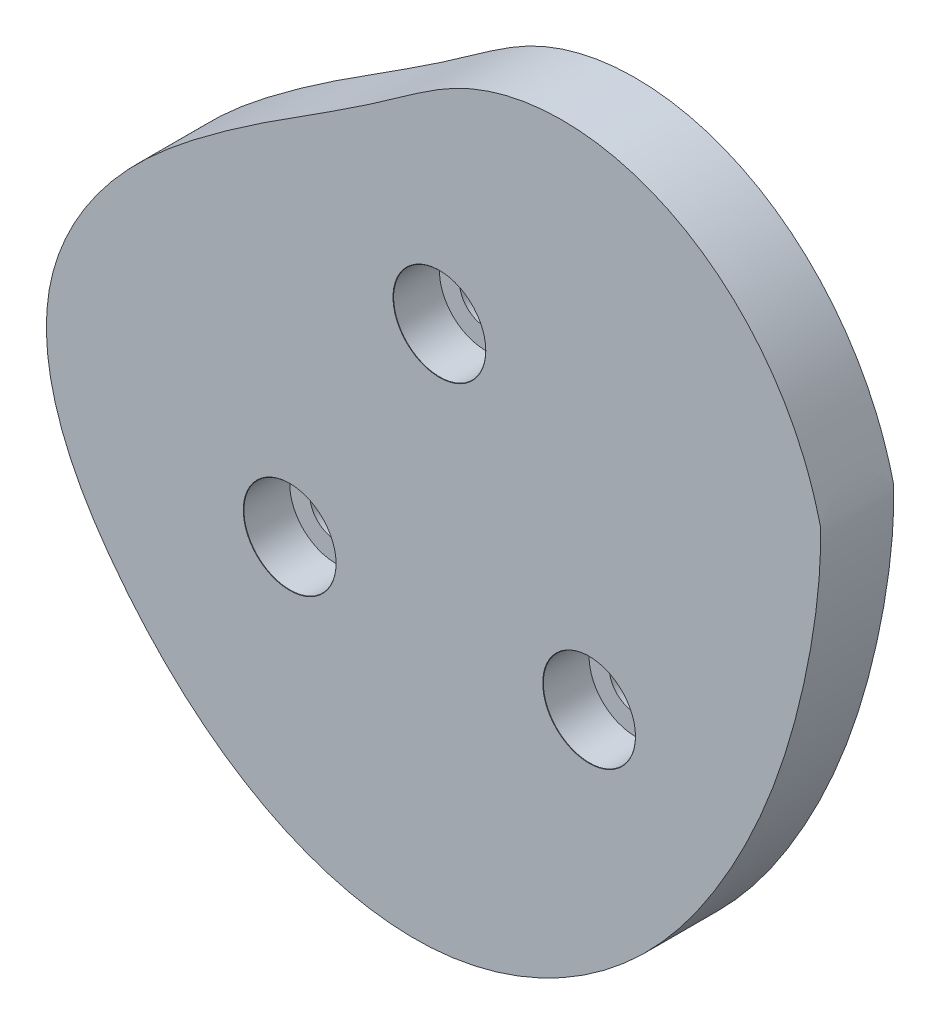
from build123d import *

# Parameters (mm, degrees)
BOSS_EXTRUDE1_DEPTH           = 3.175
CBORE_FOR_M4_SHCS1_AT_2_COUNT = 2
CBORE_FOR_M4_SHCS1_AT_2_PITCH = 25.980762114
CBORE_FOR_M4_SHCS1_AT_3_COUNT = 2
CBORE_FOR_M4_SHCS1_AT_3_PITCH = 25.980762114


with BuildPart() as part:
    # Sketch1 → Boss-Extrude1 (new body, symmetric)
    with BuildSketch(Plane.XY):
        with BuildLine():
            add(Edge.make_bspline(
                [(20.469276515, 0), (20.453926982, 0.12032637), (20.37906939, 0.354674879), (20.296830063, 0.708499092), (20.201433403, 1.058274137), (20.104513169, 1.405451482), (20.003039964, 1.749648928), (19.897882185, 2.090972241), (19.788868962, 2.429397518), (19.676103633, 2.764935406), (19.559614296, 3.097587319), (19.439446847, 3.427357), (19.315640263, 3.754247363), (19.18823323, 4.078261244), (19.057262426, 4.399401123), (18.922763033, 4.717669117), (18.784768655, 5.033066908), (18.643311395, 5.345595684), (18.498421896, 5.655256084), (18.350129388, 5.962048143), (18.198461741, 6.265971239), (18.043445514, 6.567024042), (17.885106009, 6.865204466), (17.723467325, 7.160509621), (17.558552411, 7.452935769), (17.390383125, 7.742478283), (17.218980293, 8.029131604), (17.044363762, 8.312889204), (16.866552466, 8.593743551), (16.685564483, 8.871686073), (16.501417094, 9.146707128), (16.314126853, 9.418795975), (16.123709641, 9.687940747), (15.930180735, 9.954128423), (15.73355487, 10.21734481), (15.533846304, 10.477574522), (15.331068884, 10.734800958), (15.125236108, 10.989006292), (14.916361195, 11.240171456), (14.704457148, 11.48827613), (14.48953682, 11.733298735), (14.271612982, 11.975216425), (14.050698387, 12.214005082), (13.826805837, 12.449639318), (13.599948249, 12.682092471), (13.37013872, 12.911336613), (13.137390595, 13.137342549), (12.901717528, 13.360079832), (12.66313355, 13.579516764), (12.42165313, 13.795620417), (12.177291245, 14.00835664), (11.930063436, 14.21769008), (11.679985874, 14.423584196), (11.427075422, 14.626001285), (11.171349697, 14.824902501), (10.912827125, 15.020247881), (10.651527006, 15.211996372), (10.387469571, 15.400105862), (10.120676038, 15.584533205), (9.851168668, 15.765234263), (9.578970821, 15.942163933), (9.30410701, 16.115276188), (9.026602952, 16.284524115), (8.746485624, 16.449859953), (8.463783305, 16.611235142), (8.178525632, 16.768600359), (7.890743643, 16.921905569), (7.600469825, 17.071100071), (7.307738154, 17.216132546), (7.012584144, 17.356951111), (6.71504488, 17.493503366), (6.415159063, 17.625736452), (6.112967045, 17.753597106), (5.808510864, 17.877031712), (5.501834279, 17.995986365), (5.192982801, 18.110406928), (4.882003722, 18.22023909), (4.568946147, 18.32542843), (4.253861014, 18.425920478), (3.936801123, 18.521660778), (3.617821156, 18.612594954), (3.296977698, 18.698668773), (2.974329252, 18.779828214), (2.649936258, 18.856019533), (2.323861105, 18.927189329), (1.996168144, 18.993284617), (1.666923695, 19.054252892), (1.336196056, 19.110042202), (1.004055505, 19.160601215), (0.670574308, 19.205879292), (0.335826712, 19.245826554), (-0.000111049, 19.280393959), (-0.337160764, 19.309533366), (-0.675242249, 19.33319761), (-1.014273357, 19.351340575), (-1.354169986, 19.36391726), (-1.694846096, 19.370883857), (-2.036213723, 19.372197815), (-2.378182996, 19.367817918), (-2.720662158, 19.357704349), (-3.06355759, 19.341818766), (-3.406773832, 19.320124369), (-3.750213613, 19.29258597), (-4.093777879, 19.259170061), (-4.437365826, 19.219844885), (-4.780874932, 19.174580501), (-5.124200991, 19.123348854), (-5.467238158, 19.066123837), (-5.809878982, 19.002881361), (-6.152014452, 18.933599416), (-6.493534041, 18.858258136), (-6.834325754, 18.776839862), (-7.174276174, 18.689329199), (-7.513270515, 18.595713085), (-7.851192674, 18.49598084), (-8.187925289, 18.39012423), (-8.52334979, 18.278137522), (-8.857346463, 18.160017536), (-9.18979451, 18.035763705), (-9.520572102, 17.905378106), (-9.849556485, 17.76886559), (-10.176623887, 17.626233534), (-10.501650192, 17.477492989), (-10.824508724, 17.322654615), (-11.145080224, 17.161743427), (-11.463230747, 16.994735948), (-11.779050897, 16.821987195), (-12.092717082, 16.643916451), (-12.40442328, 16.460901436), (-12.714391967, 16.273307346), (-13.022869092, 16.08147821), (-13.330124311, 15.885737879), (-13.636449754, 15.686388462), (-13.942159146, 15.48370949), (-14.247586785, 15.277956924), (-14.553086511, 15.069362251), (-14.859030639, 14.858131599), (-15.165808852, 14.64444489), (-15.473827068, 14.428455032), (-15.783506277, 14.210287148), (-16.095281345, 13.990037832), (-16.40959979, 13.767774461), (-16.72692054, 13.54353453), (-17.047712658, 13.317325034), (-17.372454053, 13.089121892), (-17.701630161, 12.858869404), (-18.035732622, 12.62647976), (-18.375257928, 12.391832591), (-18.720706063, 12.15477456), (-19.072579127, 11.915119006), (-19.43137995, 11.672645633), (-19.797610697, 11.427100253), (-20.171771452, 11.17819457), (-20.554358808, 10.925606023), (-20.94586444, 10.668977684), (-21.346773666, 10.407918194), (-21.757564012, 10.14200177), (-22.178703761, 9.870768248), (-22.6106505, 9.593723189), (-23.053849668, 9.310338029), (-23.508733094, 9.020050289), (-23.975717536, 8.722263829), (-24.455203223, 8.416349151), (-24.947572399, 8.101643764), (-25.453187868, 7.777452583), (-25.972391547, 7.443048392), (-26.505503025, 7.097672347), (-27.052818136, 6.74053453), (-27.614607536, 6.370814557), (-28.191115299, 5.98766223), (-28.782557525, 5.590198235), (-29.389120965, 5.1775149), (-30.01096166, 4.74867698), (-30.64820362, 4.302722541), (-31.300937436, 3.838663708), (-31.969219271, 3.355488182), (-32.653068482, 2.852157975), (-33.352355561, 2.327705554), (-34.066325533, 1.781561053), (-34.792156176, 1.21198818), (-35.526433511, 0.617909195), (-36.265587734, -0.001457622), (-37.006020345, -0.646671842), (-37.744112291, -1.318073183), (-38.476233993, -2.015780313), (-39.198754785, -2.739691012), (-39.908052424, -3.489482365), (-40.600522516, -4.264611377), (-41.272587879, -5.064315898), (-41.920707839, -5.8876159), (-42.541387444, -6.733315094), (-43.131186577, -7.600002901), (-43.686728957, -8.486056757), (-44.204711001, -9.389644786), (-44.681910487, -10.308728765), (-45.115195144, -11.241067557), (-45.501530481, -12.184220343), (-45.837989248, -13.135551967), (-46.121753439, -14.092231719), (-46.350171981, -15.051382919), (-46.520731563, -16.010470183), (-46.635259313, -16.966833368), (-46.695881182, -17.918707922), (-46.704758414, -18.864589252), (-46.664077675, -19.803116927), (-46.576039325, -20.733069832), (-46.442852564, -21.653366621), (-46.266728948, -22.563064411), (-46.04987654, -23.461357639), (-45.794494099, -24.347576614), (-45.502765451, -25.221185937), (-45.176853985, -26.081782762), (-44.818897277, -26.929094921), (-44.431001821, -27.762978927), (-44.015237852, -28.583417844), (-43.57363427, -29.390519034), (-43.108173634, -30.184511764), (-42.620787267, -30.965744674), (-42.113350378, -31.734683158), (-41.587677508, -32.491906358), (-41.045517213, -33.238104962), (-40.488554103, -33.974069902), (-39.918413965, -34.700676565), (-39.33481729, -35.417341816), (-38.737534614, -36.123431266), (-38.126368953, -36.818284488), (-37.501156774, -37.501216811), (-36.861768424, -38.171521432), (-36.208109378, -38.828470556), (-35.54012122, -39.471316853), (-34.857782619, -40.099294871), (-34.161110261, -40.711622507), (-33.450159719, -41.307502509), (-32.725026287, -41.886124006), (-31.985845748, -42.446664075), (-31.232795105, -42.98828933), (-30.466093242, -43.510157547), (-29.686001549, -44.011419305), (-28.892824481, -44.491219662), (-28.08691006, -44.948699845), (-27.268650333, -45.382998964), (-26.438481761, -45.793255749), (-25.596885557, -46.178610297), (-24.744387965, -46.538205845), (-23.881560483, -46.871190547), (-23.009020024, -47.176719273), (-22.127429019, -47.45395541), (-21.237495463, -47.702072683), (-20.339972901, -47.920256977), (-19.435660354, -48.10770816), (-18.525402181, -48.263641942), (-17.610087896, -48.387291641), (-16.690651874, -48.477910274), (-15.768073177, -48.534771472), (-14.84337466, -48.55717479), (-13.917624463, -48.544434556), (-12.991941631, -48.495930985), (-12.067628664, -48.41094298), (-11.146068248, -48.290046351), (-10.228680944, -48.134143741), (-9.316882792, -47.944122816), (-8.412028473, -47.72093942), (-7.515412754, -47.465590968), (-6.62826823, -47.179120315), (-5.751764231, -46.862611411), (-4.88700552, -46.517187103), (-4.03503117, -46.144006323), (-3.196813506, -45.744261393), (-2.373257143, -45.319175263), (-1.565198119, -44.86999873), (-0.773403127, -44.398007635), (0.001431168, -43.904500034), (0.758678706, -43.390793354), (1.497784521, -42.858221534), (2.218265124, -42.308132156), (2.919708798, -41.74188356), (3.601775788, -41.160841961), (4.2641984, -40.566378558), (4.906780999, -39.959866645), (5.529399907, -39.342678725), (6.132003211, -38.716183626), (6.714610467, -38.081743631), (7.277312313, -37.440711615), (7.82026998, -36.794428197), (8.343714715, -36.144218914), (8.847947092, -35.491391398), (9.333336294, -34.837232621), (9.800319062, -34.183006019), (10.24939942, -33.529949158), (10.681145161, -32.879269558), (11.096195715, -32.232147378), (11.49523197, -31.589707036), (11.879149859, -30.952992781), (12.248517048, -30.322552069), (12.603694342, -29.698556098), (12.945153788, -29.0811272), (13.273344314, -28.470359529), (13.588713491, -27.866335339), (13.891701075, -27.269121707), (14.182740239, -26.678771864), (14.462256803, -26.095325337), (14.730669009, -25.518808409), (14.988387177, -24.949234509), (15.2358134, -24.386604625), (15.473341258, -23.830907716), (15.701355534, -23.282121139), (15.920231962, -22.740211075), (16.130336972, -22.205132959), (16.332027463, -21.676831916), (16.525650586, -21.155243203), (16.711543541, -20.640292652), (16.890033391, -20.131897115), (17.061436892, -19.629964916), (17.226060335, -19.134396296), (17.384199405, -18.645083873), (17.536139055, -18.161913089), (17.682153396, -17.684762669), (17.822505599, -17.213505075), (17.957447815, -16.748006957), (18.087221108, -16.288129613), (18.212055405, -15.833729436), (18.332169455, -15.384658369), (18.447770812, -14.940764355), (18.559055824, -14.501891782), (18.666209639, -14.067881928), (18.769406229, -13.638573405), (18.868808423, -13.213802595), (18.964567955, -12.793404083), (19.056825528, -12.37721109), (19.14571089, -11.965055896), (19.231342923, -11.556770257), (19.313829749, -11.152185827), (19.393268841, -10.751134561), (19.469747157, -10.353449118), (19.543341277, -9.95896326), (19.614117561, -9.567512236), (19.682132311, -9.178933172), (19.747431952, -8.793065437), (19.810053221, -8.409751015), (19.870023364, -8.028834861), (19.927360353, -7.650165254), (19.982073105, -7.273594135), (20.034161718, -6.898977439), (20.083617711, -6.526175422), (20.130424277, -6.15505297), (20.174556549, -5.785479904), (20.215981868, -5.417331275), (20.254660065, -5.050487643), (20.290543747, -4.684835353), (20.323578606, -4.320266795), (20.353703685, -3.956680655), (20.380851823, -3.593982143), (20.404949486, -3.232083278), (20.425918912, -2.87090287), (20.443671673, -2.510367615), (20.458134208, -2.150408957), (20.469154396, -1.790975662), (20.476850973, -1.431987855), (20.480314085, -1.073508931), (20.482447125, -0.715105964), (20.47192834, -0.358233383), (20.484273463, -0.11756243), (20.469276515, 0)],
                knots=[0, 0, 0, 0, 0.001764203, 0.003519492, 0.005266096, 0.007004244, 0.008734164, 0.010456082, 0.01217022, 0.013876802, 0.015576046, 0.017268173, 0.018953398, 0.020631935, 0.022303998, 0.023969797, 0.025629542, 0.027283438, 0.02893169, 0.030574501, 0.032212071, 0.033844598, 0.035472279, 0.037095307, 0.038713875, 0.04032817, 0.041938381, 0.043544692, 0.045147285, 0.046746342, 0.048342038, 0.04993455, 0.05152405, 0.053110709, 0.054694695, 0.056276173, 0.057855307, 0.059432256, 0.061007179, 0.062580232, 0.064151567, 0.065721335, 0.067289683, 0.068856757, 0.070422701, 0.071987653, 0.073551752, 0.075115133, 0.076677929, 0.078240269, 0.079802281, 0.08136409, 0.082925818, 0.084487586, 0.08604951, 0.087611705, 0.089174283, 0.090737355, 0.092301027, 0.093865405, 0.09543059, 0.096996683, 0.09856378, 0.100131977, 0.101701366, 0.103272038, 0.10484408, 0.106417578, 0.107992614, 0.109569269, 0.111147622, 0.112727748, 0.114309722, 0.115893614, 0.117479494, 0.11906743, 0.120657485, 0.122249722, 0.123844203, 0.125440984, 0.127040123, 0.128641672, 0.130245685, 0.13185221, 0.133461296, 0.135072989, 0.136687331, 0.138304365, 0.139924131, 0.141546665, 0.143172005, 0.144800184, 0.146431233, 0.148065183, 0.149702063, 0.151341898, 0.152984714, 0.154630532, 0.156279374, 0.157931258, 0.159586203, 0.161244224, 0.162905335, 0.164569548, 0.166236874, 0.167907321, 0.169580897, 0.171257607, 0.172937454, 0.174620442, 0.176306572, 0.177995841, 0.179688248, 0.181383788, 0.183082456, 0.184784246, 0.186489147, 0.188197151, 0.189908245, 0.191622417, 0.193339652, 0.195059933, 0.196783244, 0.198509566, 0.200238878, 0.201971181, 0.203706635, 0.205445504, 0.2071881, 0.208934793, 0.210686019, 0.212442285, 0.214204179, 0.215972379, 0.217747655, 0.219530879, 0.221323028, 0.223125194, 0.224938584, 0.226764524, 0.228604465, 0.230459983, 0.232332781, 0.234224685, 0.236137652, 0.238073757, 0.2400352, 0.242024293, 0.244043462, 0.246095238, 0.248182252, 0.250307226, 0.252472967, 0.254682362, 0.256938364, 0.259243991, 0.261602312, 0.264016447, 0.266489554, 0.269024826, 0.271625481, 0.274294763, 0.277035933, 0.279852264, 0.282747038, 0.285723547, 0.288785083, 0.291934943, 0.295176421, 0.298512813, 0.30194741, 0.305483503, 0.309124377, 0.312873317, 0.316733603, 0.320708513, 0.324801324, 0.329015309, 0.333351662, 0.33780314, 0.342360129, 0.347012767, 0.351751024, 0.35656476, 0.361443788, 0.366377916, 0.371356998, 0.376370977, 0.381409928, 0.386464106, 0.391523993, 0.396580347, 0.401624264, 0.406647238, 0.411641236, 0.416598779, 0.421513038, 0.426377942, 0.431188305, 0.435939966, 0.440631828, 0.445270717, 0.449864684, 0.454421044, 0.458946377, 0.463446541, 0.467926691, 0.472391308, 0.476844238, 0.481288728, 0.48572748, 0.490162693, 0.494596121, 0.499029126, 0.50346273, 0.507897674, 0.512334472, 0.516773466, 0.521214882, 0.525658883, 0.530105625, 0.534555313, 0.539008153, 0.543464074, 0.5479229, 0.552384417, 0.556848379, 0.561314515, 0.565782528, 0.570252105, 0.57472292, 0.579194639, 0.583666924, 0.588139439, 0.592611855, 0.597083853, 0.601555132, 0.606025412, 0.610494439, 0.614961992, 0.619427887, 0.623891985, 0.628354194, 0.632814475, 0.637272853, 0.641729416, 0.646184326, 0.650637823, 0.655090233, 0.659541971, 0.663993554, 0.668445597, 0.672898832, 0.677354104, 0.681812384, 0.68627477, 0.690742499, 0.695216754, 0.699697325, 0.704183213, 0.708673274, 0.713166232, 0.71766069, 0.722155137, 0.726647962, 0.731137456, 0.735621826, 0.7400992, 0.744567632, 0.749025113, 0.753469575, 0.757898896, 0.762310907, 0.766703399, 0.771074124, 0.775420805, 0.779741136, 0.784032793, 0.788293433, 0.792520702, 0.796712241, 0.800865688, 0.804978687, 0.809048891, 0.813073968, 0.817051612, 0.820979544, 0.824855525, 0.82867736, 0.832442913, 0.836150111, 0.839796963, 0.843381676, 0.84690413, 0.850365453, 0.853766802, 0.857109335, 0.860394205, 0.863622561, 0.866795554, 0.86991433, 0.872980033, 0.875993807, 0.878956793, 0.881870128, 0.88473495, 0.887552392, 0.890323587, 0.893049665, 0.895731754, 0.898370977, 0.900968457, 0.903525314, 0.906042661, 0.908521612, 0.910963275, 0.913368751, 0.915739141, 0.918075538, 0.920379029, 0.922650695, 0.924891611, 0.927102843, 0.929285451, 0.931440483, 0.93356898, 0.935671971, 0.937750475, 0.939805498, 0.941838034, 0.943849063, 0.945839551, 0.947810449, 0.949762689, 0.95169719, 0.953614851, 0.955516554, 0.957403159, 0.959275508, 0.961134423, 0.962980703, 0.964815124, 0.966638443, 0.96845139, 0.970254675, 0.972048981, 0.973834969, 0.975613274, 0.977384508, 0.979149256, 0.980908081, 0.982661518, 0.984410078, 0.98615425, 0.987894493, 0.989631248, 0.991364926, 0.993095918, 0.994824589, 0.996551283, 0.998276321, 1, 1, 1, 1], degree=3))
        make_face()
    extrude(amount=BOSS_EXTRUDE1_DEPTH, both=True)

    # Sketch7 → CBORE for M4 SHCS1 (revolve, cut)
    with BuildSketch(Plane(origin=(-12.593900177, -1.272585975, 3.175), x_dir=(0, -1, 0), z_dir=(1, 0, 0))):
        Polygon((0, 0), (0, 6.35), (2.25, 6.35), (2.25, 4), (4, 4), (4, 0.025), (4.025, 0), align=None)
    cbore_for_m4_shcs1 = revolve(axis=Axis((-12.593900177, -1.272585975, 9.525), (0, 0, -1)), mode=Mode.SUBTRACT)

    # CBORE for M4 SHCS1 at 2: CBORE for M4 SHCS1 ×2
    with Locations(*[Vector(0.5, -0.866025404, 0) * (i * CBORE_FOR_M4_SHCS1_AT_2_PITCH) for i in range(1, CBORE_FOR_M4_SHCS1_AT_2_COUNT)]):
        add(cbore_for_m4_shcs1, mode=Mode.SUBTRACT)

    # CBORE for M4 SHCS1 at 3: CBORE for M4 SHCS1 ×2
    with Locations(*[Vector(-0.5, -0.866025404, 0) * (i * CBORE_FOR_M4_SHCS1_AT_3_PITCH) for i in range(1, CBORE_FOR_M4_SHCS1_AT_3_COUNT)]):
        add(cbore_for_m4_shcs1, mode=Mode.SUBTRACT)


solid = part.part
